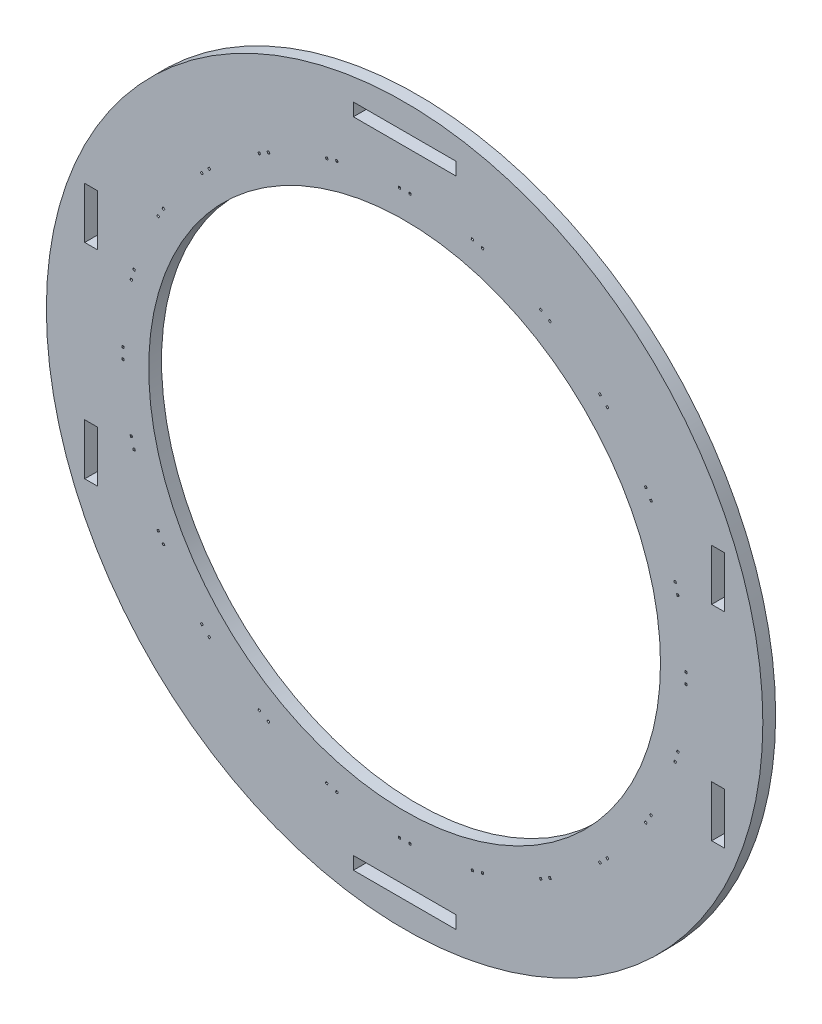
from build123d import *

# Parameters (mm, degrees)
SKETCH1_R           = 88.9
SKETCH1_R_2         = 63.5
SKETCH1_W           = 0.5334
SKETCH1_H           = 0.5334
SKETCH1_W_2         = 3.175
SKETCH1_H_2         = 12.7
SKETCH1_W_3         = 25.4
SKETCH1_H_3         = 3.175
BOSS_EXTRUDE1_DEPTH = 3.175


with BuildPart() as part:
    # Sketch1 → Boss-Extrude1 (new body)
    with BuildSketch(Plane.XY):
        Circle(SKETCH1_R)
        Circle(SKETCH1_R_2, mode=Mode.SUBTRACT)
        with Locations((-1.30175, 69.85)):
            Rectangle(SKETCH1_W, SKETCH1_H, mode=Mode.SUBTRACT)
        with Locations((1.30175, 69.85)):
            Rectangle(SKETCH1_W, SKETCH1_H, mode=Mode.SUBTRACT)
        Polygon((16.632530977, 68.133476115), (17.147755813, 67.995422037), (17.009701735, 67.480197201), (16.494476899, 67.61825128), align=None, mode=Mode.SUBTRACT)
        Polygon((19.147318866, 67.459640732), (19.009264788, 66.944415896), (19.524489623, 66.806361817), (19.662543702, 67.321586653), align=None, mode=Mode.SUBTRACT)
        Polygon((33.700032455, 61.50706843), (34.161970406, 61.24036843), (33.895270406, 60.778430479), (33.433332455, 61.045130479), align=None, mode=Mode.SUBTRACT)
        Polygon((35.954729594, 60.20531843), (35.688029594, 59.743380479), (36.149967545, 59.476680479), (36.416667545, 59.93861843), align=None, mode=Mode.SUBTRACT)
        Polygon((48.470932413, 50.689055675), (48.848103171, 50.311884918), (48.470932413, 49.934714161), (48.093761656, 50.311884918), align=None, mode=Mode.SUBTRACT)
        Polygon((50.311884918, 48.848103171), (49.934714161, 48.470932413), (50.311884918, 48.093761656), (50.689055675, 48.470932413), align=None, mode=Mode.SUBTRACT)
        Polygon((59.93861843, 36.416667545), (60.20531843, 35.954729594), (59.743380479, 35.688029594), (59.476680479, 36.149967545), align=None, mode=Mode.SUBTRACT)
        Polygon((61.24036843, 34.161970406), (60.778430479, 33.895270406), (61.045130479, 33.433332455), (61.50706843, 33.700032455), align=None, mode=Mode.SUBTRACT)
        Polygon((67.321586653, 19.662543702), (67.459640732, 19.147318866), (66.944415896, 19.009264788), (66.806361817, 19.524489623), align=None, mode=Mode.SUBTRACT)
        Polygon((67.995422037, 17.147755813), (67.480197201, 17.009701735), (67.61825128, 16.494476899), (68.133476115, 16.632530977), align=None, mode=Mode.SUBTRACT)
        with Locations((69.85, 1.30175)):
            Rectangle(SKETCH1_W, SKETCH1_H, mode=Mode.SUBTRACT)
        with Locations((69.85, -1.30175)):
            Rectangle(SKETCH1_W, SKETCH1_H, mode=Mode.SUBTRACT)
        Polygon((68.133476115, -16.632530977), (67.995422037, -17.147755813), (67.480197201, -17.009701735), (67.61825128, -16.494476899), align=None, mode=Mode.SUBTRACT)
        Polygon((67.459640732, -19.147318866), (66.944415896, -19.009264788), (66.806361817, -19.524489623), (67.321586653, -19.662543702), align=None, mode=Mode.SUBTRACT)
        Polygon((61.50706843, -33.700032455), (61.24036843, -34.161970406), (60.778430479, -33.895270406), (61.045130479, -33.433332455), align=None, mode=Mode.SUBTRACT)
        Polygon((60.20531843, -35.954729594), (59.743380479, -35.688029594), (59.476680479, -36.149967545), (59.93861843, -36.416667545), align=None, mode=Mode.SUBTRACT)
        Polygon((50.689055675, -48.470932413), (50.311884918, -48.848103171), (49.934714161, -48.470932413), (50.311884918, -48.093761656), align=None, mode=Mode.SUBTRACT)
        Polygon((48.848103171, -50.311884918), (48.470932413, -49.934714161), (48.093761656, -50.311884918), (48.470932413, -50.689055675), align=None, mode=Mode.SUBTRACT)
        Polygon((36.416667545, -59.93861843), (35.954729594, -60.20531843), (35.688029594, -59.743380479), (36.149967545, -59.476680479), align=None, mode=Mode.SUBTRACT)
        Polygon((34.161970406, -61.24036843), (33.895270406, -60.778430479), (33.433332455, -61.045130479), (33.700032455, -61.50706843), align=None, mode=Mode.SUBTRACT)
        Polygon((19.662543702, -67.321586653), (19.147318866, -67.459640732), (19.009264788, -66.944415896), (19.524489623, -66.806361817), align=None, mode=Mode.SUBTRACT)
        Polygon((17.147755813, -67.995422037), (17.009701735, -67.480197201), (16.494476899, -67.61825128), (16.632530977, -68.133476115), align=None, mode=Mode.SUBTRACT)
        with Locations((1.30175, -69.85)):
            Rectangle(SKETCH1_W, SKETCH1_H, mode=Mode.SUBTRACT)
        with Locations((-1.30175, -69.85)):
            Rectangle(SKETCH1_W, SKETCH1_H, mode=Mode.SUBTRACT)
        Polygon((-16.632530977, -68.133476115), (-17.147755813, -67.995422037), (-17.009701735, -67.480197201), (-16.494476899, -67.61825128), align=None, mode=Mode.SUBTRACT)
        Polygon((-19.147318866, -67.459640732), (-19.009264788, -66.944415896), (-19.524489623, -66.806361817), (-19.662543702, -67.321586653), align=None, mode=Mode.SUBTRACT)
        Polygon((-33.700032455, -61.50706843), (-34.161970406, -61.24036843), (-33.895270406, -60.778430479), (-33.433332455, -61.045130479), align=None, mode=Mode.SUBTRACT)
        Polygon((-35.954729594, -60.20531843), (-35.688029594, -59.743380479), (-36.149967545, -59.476680479), (-36.416667545, -59.93861843), align=None, mode=Mode.SUBTRACT)
        Polygon((-48.470932413, -50.689055675), (-48.848103171, -50.311884918), (-48.470932413, -49.934714161), (-48.093761656, -50.311884918), align=None, mode=Mode.SUBTRACT)
        Polygon((-50.311884918, -48.848103171), (-49.934714161, -48.470932413), (-50.311884918, -48.093761656), (-50.689055675, -48.470932413), align=None, mode=Mode.SUBTRACT)
        Polygon((-59.93861843, -36.416667545), (-60.20531843, -35.954729594), (-59.743380479, -35.688029594), (-59.476680479, -36.149967545), align=None, mode=Mode.SUBTRACT)
        Polygon((-61.24036843, -34.161970406), (-60.778430479, -33.895270406), (-61.045130479, -33.433332455), (-61.50706843, -33.700032455), align=None, mode=Mode.SUBTRACT)
        Polygon((-67.321586653, -19.662543702), (-67.459640732, -19.147318866), (-66.944415896, -19.009264788), (-66.806361817, -19.524489623), align=None, mode=Mode.SUBTRACT)
        Polygon((-67.995422037, -17.147755813), (-67.480197201, -17.009701735), (-67.61825128, -16.494476899), (-68.133476115, -16.632530977), align=None, mode=Mode.SUBTRACT)
        with Locations((-69.85, -1.30175)):
            Rectangle(SKETCH1_W, SKETCH1_H, mode=Mode.SUBTRACT)
        with Locations((-69.85, 1.30175)):
            Rectangle(SKETCH1_W, SKETCH1_H, mode=Mode.SUBTRACT)
        Polygon((-68.133476115, 16.632530977), (-67.995422037, 17.147755813), (-67.480197201, 17.009701735), (-67.61825128, 16.494476899), align=None, mode=Mode.SUBTRACT)
        Polygon((-67.459640732, 19.147318866), (-66.944415896, 19.009264788), (-66.806361817, 19.524489623), (-67.321586653, 19.662543702), align=None, mode=Mode.SUBTRACT)
        Polygon((-61.50706843, 33.700032455), (-61.24036843, 34.161970406), (-60.778430479, 33.895270406), (-61.045130479, 33.433332455), align=None, mode=Mode.SUBTRACT)
        Polygon((-60.20531843, 35.954729594), (-59.743380479, 35.688029594), (-59.476680479, 36.149967545), (-59.93861843, 36.416667545), align=None, mode=Mode.SUBTRACT)
        Polygon((-50.689055675, 48.470932413), (-50.311884918, 48.848103171), (-49.934714161, 48.470932413), (-50.311884918, 48.093761656), align=None, mode=Mode.SUBTRACT)
        Polygon((-48.848103171, 50.311884918), (-48.470932413, 49.934714161), (-48.093761656, 50.311884918), (-48.470932413, 50.689055675), align=None, mode=Mode.SUBTRACT)
        Polygon((-36.416667545, 59.93861843), (-35.954729594, 60.20531843), (-35.688029594, 59.743380479), (-36.149967545, 59.476680479), align=None, mode=Mode.SUBTRACT)
        Polygon((-34.161970406, 61.24036843), (-33.895270406, 60.778430479), (-33.433332455, 61.045130479), (-33.700032455, 61.50706843), align=None, mode=Mode.SUBTRACT)
        Polygon((-19.662543702, 67.321586653), (-19.147318866, 67.459640732), (-19.009264788, 66.944415896), (-19.524489623, 66.806361817), align=None, mode=Mode.SUBTRACT)
        Polygon((-17.147755813, 67.995422037), (-17.009701735, 67.480197201), (-16.494476899, 67.61825128), (-16.632530977, 68.133476115), align=None, mode=Mode.SUBTRACT)
        with Locations((77.7875, 25.38476)):
            Rectangle(SKETCH1_W_2, SKETCH1_H_2, mode=Mode.SUBTRACT)
        with Locations((77.7875, -25.41524)):
            Rectangle(SKETCH1_W_2, SKETCH1_H_2, mode=Mode.SUBTRACT)
        with Locations((-77.7875, -25.41524)):
            Rectangle(SKETCH1_W_2, SKETCH1_H_2, mode=Mode.SUBTRACT)
        with Locations((-77.7875, 25.38476)):
            Rectangle(SKETCH1_W_2, SKETCH1_H_2, mode=Mode.SUBTRACT)
        with Locations((0, 80.9625)):
            Rectangle(SKETCH1_W_3, SKETCH1_H_3, mode=Mode.SUBTRACT)
        with Locations((0, -80.9625)):
            Rectangle(SKETCH1_W_3, SKETCH1_H_3, mode=Mode.SUBTRACT)
    extrude(amount=BOSS_EXTRUDE1_DEPTH)


solid = part.part
